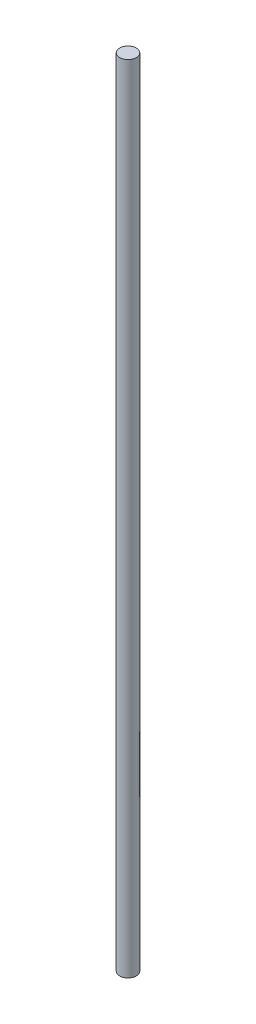
from build123d import *

# Parameters (mm, degrees)
SKETCH1_R           = 4
BOSS_EXTRUDE1_DEPTH = 382


with BuildPart() as part:
    # Sketch1 → Boss-Extrude1 (new body)
    with BuildSketch(Plane(origin=(0, 0, 0), x_dir=(1, 0, 0), z_dir=(0, 1, 0))):
        Circle(SKETCH1_R)
    extrude(amount=BOSS_EXTRUDE1_DEPTH)


solid = part.part
